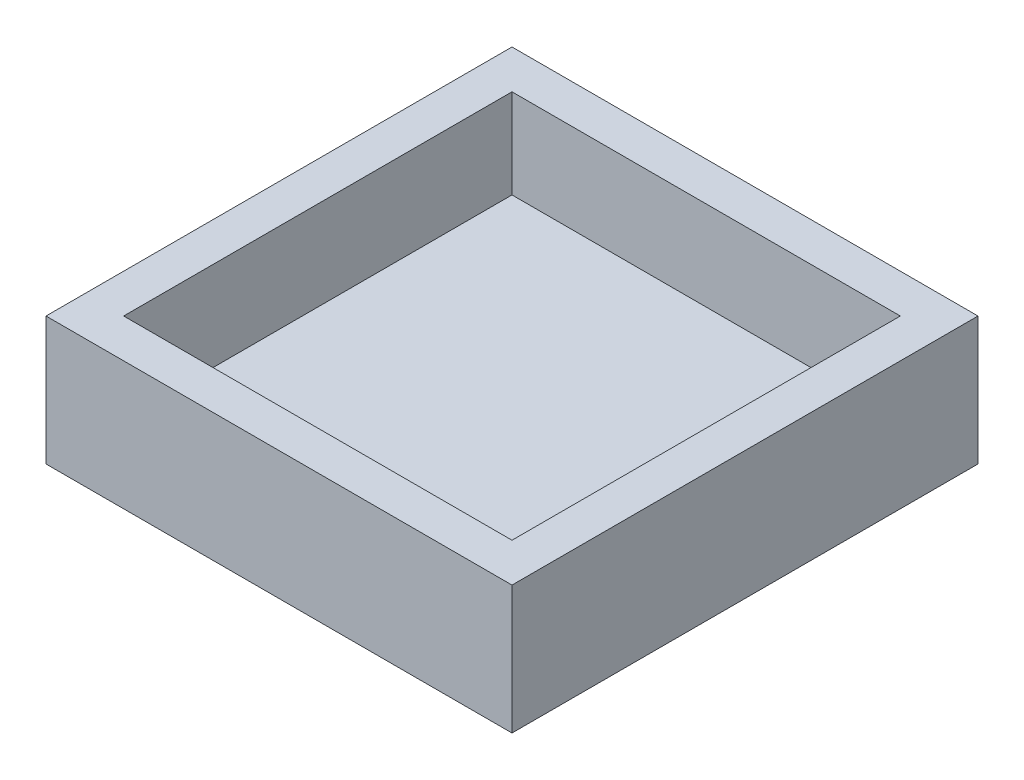
from build123d import *

# Parameters (mm, degrees)
SKETCH2_W           = 120
SKETCH2_H           = 120
BOSS_EXTRUDE1_DEPTH = 33
SHELL1_T            = -10


with BuildPart() as part:
    # Sketch2 → Boss-Extrude1 (new body)
    with BuildSketch(Plane(origin=(0, 0, 0), x_dir=(1, 0, 0), z_dir=(0, 1, 0))):
        with Locations((5.389221557, -6.467065868)):
            Rectangle(SKETCH2_W, SKETCH2_H)
    extrude(amount=BOSS_EXTRUDE1_DEPTH)

    # Shell1
    shell1_openings = [part.faces().sort_by_distance(p)[0] for p in [
        (5.389221557, 33, 6.467065868),
    ]]
    offset(amount=SHELL1_T, openings=shell1_openings, kind=Kind.INTERSECTION)


solid = part.part
